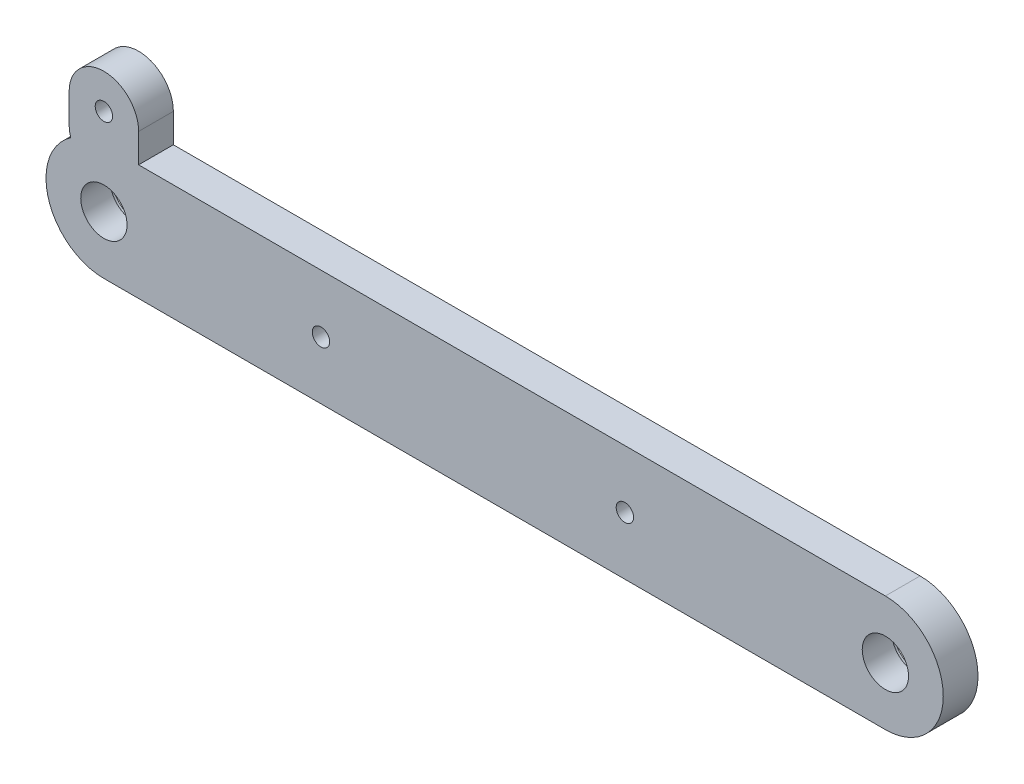
from build123d import *

# Parameters (mm, degrees)
SKETCH_1_R                   = 4
EXTRUDE_1_DEPTH              = 6
HOLE_WIZARD_M5_1_D           = 8
HOLE_WIZARD_M5_1_CBORE_D     = 9.5
HOLE_WIZARD_M5_1_CBORE_DEPTH = 0.9
SKETCH_7_R                   = 1.5
CUT_EXTRUDE_1_DEPTH          = 1
CUT_EXTRUDE_1_DEPTH_BACK     = 7


with BuildPart() as part:
    # 草图1 → 凸台-拉伸1 (new body)
    with BuildSketch(Plane.XY):
        with BuildLine():
            Line((0, 10), (135, 10))
            ThreePointArc((135, 10), (145, 0), (135, -10))
            Line((135, -10), (0, -10))
            ThreePointArc((0, -10), (-10, 0), (0, 10))
        make_face()
        with Locations((135, 0)):
            Circle(SKETCH_1_R, mode=Mode.SUBTRACT)
        Circle(SKETCH_1_R, mode=Mode.SUBTRACT)
        with BuildLine():
            Line((-6, 10), (-6, 15))
            ThreePointArc((-6, 15), (0, 21), (6, 15))
            Line((6, 15), (6, 10))
            ThreePointArc((6, 10), (0, 4), (-6, 10))
        make_face()
    extrude(amount=EXTRUDE_1_DEPTH)

    # M5 六角头螺栓的柱形沉头孔1 (through all)
    with Locations(Plane(origin=(0, 0, 0), x_dir=(-1, 0, 0), z_dir=(0, 0, -1))):
        with Locations((-135, 0), (0, 0)):
            CounterBoreHole(HOLE_WIZARD_M5_1_D / 2, HOLE_WIZARD_M5_1_CBORE_D / 2, HOLE_WIZARD_M5_1_CBORE_DEPTH)

    # 草图7 → 切除-拉伸1 (cut, two sides)
    with BuildSketch(Plane(origin=(0, 0, 0), x_dir=(-1, 0, 0), z_dir=(0, 0, -1))) as cut_extrude_1_sk:
        with Locations((-37.5, 0)):
            Circle(SKETCH_7_R)
        with Locations((-90, 0)):
            Circle(SKETCH_7_R)
        with Locations((0, 15)):
            Circle(SKETCH_7_R)
    extrude(amount=CUT_EXTRUDE_1_DEPTH, mode=Mode.SUBTRACT)
    extrude(cut_extrude_1_sk.sketch, amount=-CUT_EXTRUDE_1_DEPTH_BACK, mode=Mode.SUBTRACT)


solid = part.part
